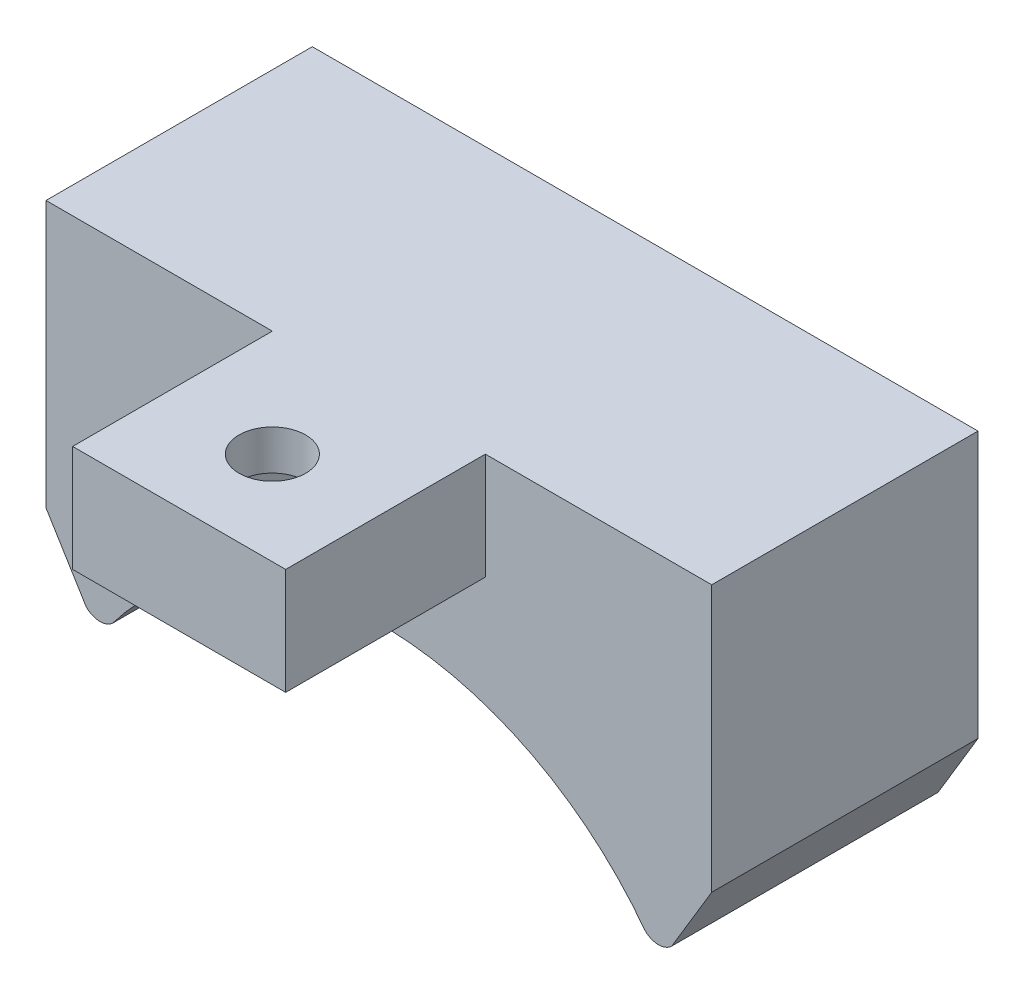
from build123d import *

# Parameters (mm, degrees)
BOSS_EXTRUDE1_DEPTH = 20
BOSS_EXTRUDE2_DEPTH = 15
CUT_EXTRUDE1_DEPTH  = 5
SKETCH5_R           = 2.5
CUT_EXTRUDE2_DEPTH  = 3


with BuildPart() as part:
    # Sketch1 → Boss-Extrude1 (new body)
    with BuildSketch(Plane.XY):
        with BuildLine():
            Line((-25, 10), (25, 10))
            Line((25, 10), (25, -10))
            Line((25, -10), (22, -15))
            ThreePointArc((22, -15), (21, -15.414213562), (20, -15))
            ThreePointArc((20, -15), (0, -5.003320801), (-20, -15))
            ThreePointArc((-20, -15), (-21.018204397, -15.363175427), (-21.994987437, -14.9))
            Line((-21.994987437, -14.9), (-25, -10))
            Line((-25, -10), (-25, 10))
        make_face()
    extrude(amount=BOSS_EXTRUDE1_DEPTH)

    # Sketch2 → Boss-Extrude2 (add)
    with BuildSketch(Plane.XY.offset(20)):
        Polygon((0, 10), (-8, 10), (-8, 2), (8, 2), (8, 10), align=None)
    extrude(amount=BOSS_EXTRUDE2_DEPTH)

    # Sketch4 → Cut-Extrude1 (cut)
    with BuildSketch(Plane.XZ.offset(-2)):
        Polygon((2.457286371, 23.755949434), (4.900734659, 28.011873987), (2.436720023, 32.255924553), (-2.4707429, 32.244050566), (-4.914191188, 27.988126013), (-2.450176552, 23.744075447), align=None)
    extrude(amount=-CUT_EXTRUDE1_DEPTH, mode=Mode.SUBTRACT)

    # Sketch5 → Cut-Extrude2 (cut)
    with BuildSketch(Plane.XZ.offset(-7)):
        with Locations((0, 28.00001244)):
            Circle(SKETCH5_R)
    extrude(amount=-CUT_EXTRUDE2_DEPTH, mode=Mode.SUBTRACT)


solid = part.part
